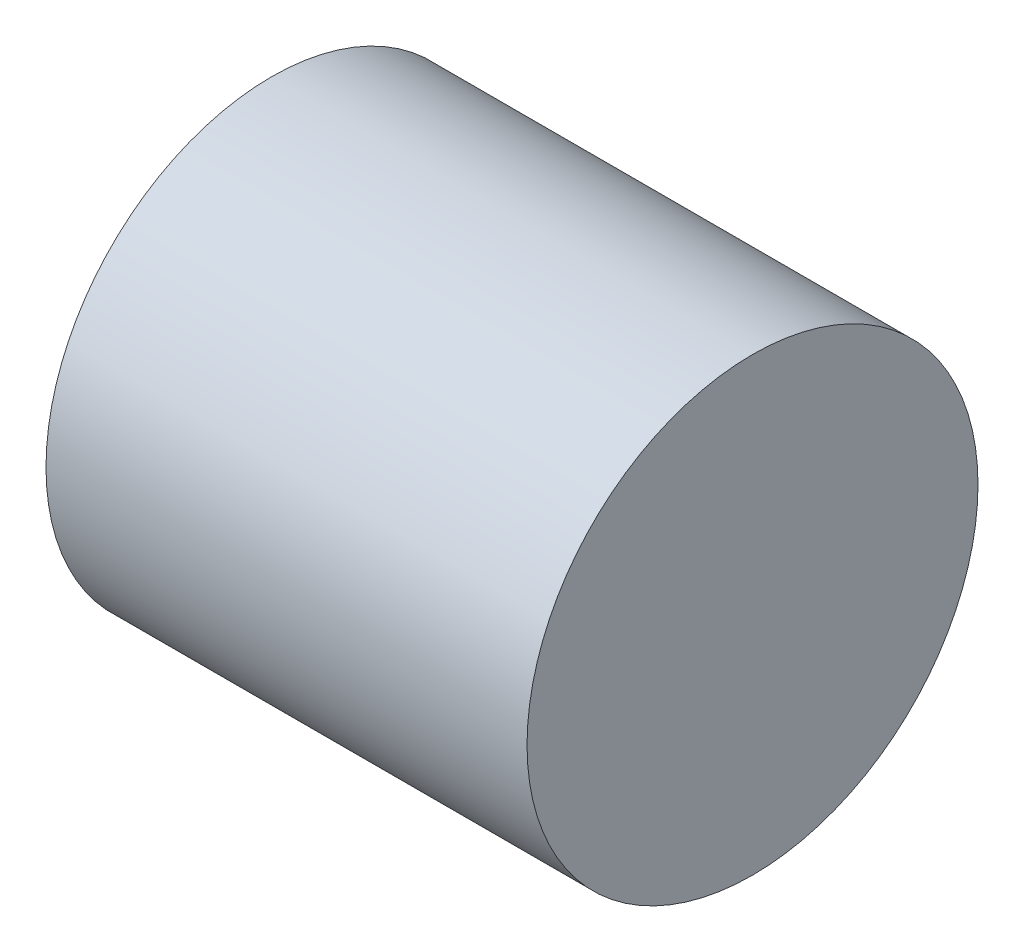
from build123d import *


with BuildPart() as part:
    # Sketch1 → Revolve1 (revolve)
    with BuildSketch(Plane.XY):
        Polygon((17.685185185, 0), (17.685185185, 15), (-14.314814815, 15), (-14.314814815, 1), (-12.314814815, 1), (-12.314814815, 0), align=None)
    revolve(axis=Axis((-19.537037037, 0, 0), (1, 0, 0)))


solid = part.part
